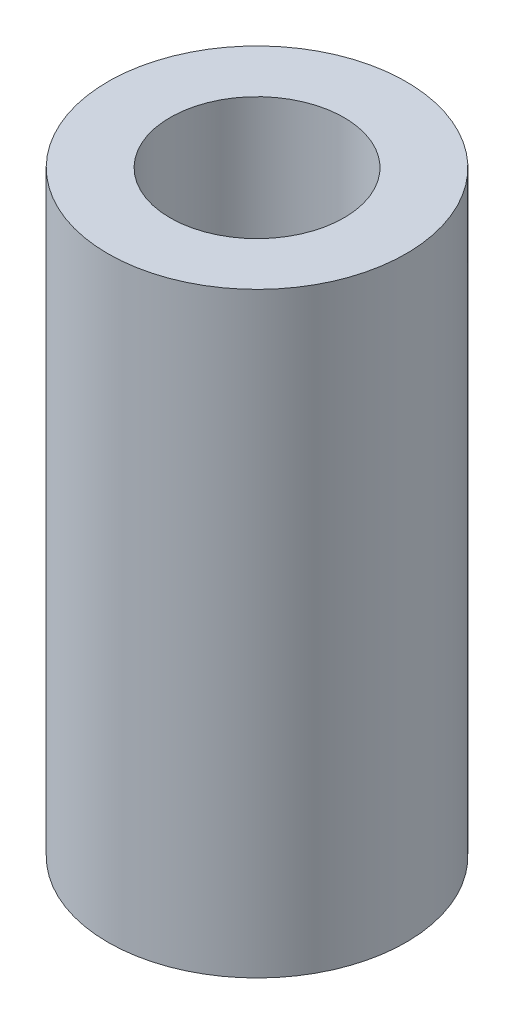
from build123d import *

# Parameters (mm, degrees)
SKETCH1_R           = 3
SKETCH1_R_2         = 1.75
BOSS_EXTRUDE1_DEPTH = 12


with BuildPart() as part:
    # Sketch1 → Boss-Extrude1 (new body)
    with BuildSketch(Plane(origin=(0, 0, 0), x_dir=(1, 0, 0), z_dir=(0, 1, 0))):
        Circle(SKETCH1_R)
        Circle(SKETCH1_R_2, mode=Mode.SUBTRACT)
    extrude(amount=BOSS_EXTRUDE1_DEPTH)


solid = part.part
